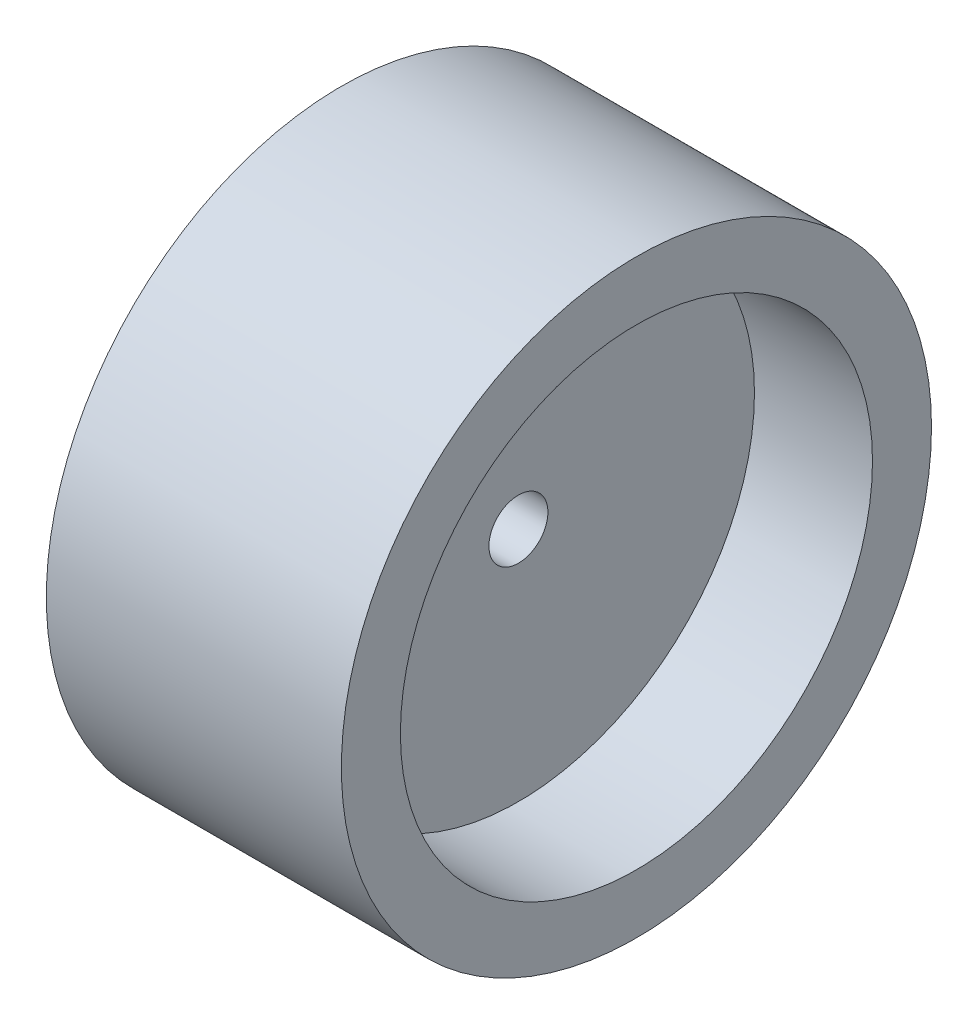
from build123d import *

# Parameters (mm, degrees)
SKETCH1_R           = 50
SKETCH1_R_2         = 5
BOSS_EXTRUDE1_DEPTH = 25
CUT_EXTRUDE1_START  = -5
SKETCH3_R           = 40
CUT_EXTRUDE1_DEPTH  = 20
CUT_EXTRUDE2_START  = 25
SKETCH3_2_R         = 40
CUT_EXTRUDE2_DEPTH  = 20


with BuildPart() as part:
    # Sketch1 → Boss-Extrude1 (new, symmetric)
    with BuildSketch(Plane(origin=(0, 0, 0), x_dir=(0, 0, -1), z_dir=(1, 0, 0))):
        Circle(SKETCH1_R)
        Circle(SKETCH1_R_2, mode=Mode.SUBTRACT)
    extrude(amount=BOSS_EXTRUDE1_DEPTH, both=True)

    # Sketch3 → Cut-Extrude1 (cut)
    with BuildSketch(Plane(origin=(0, 0, 0), x_dir=(0, 0, -1), z_dir=(1, 0, 0)).offset(CUT_EXTRUDE1_START)):
        Circle(SKETCH3_R)
    extrude(amount=-CUT_EXTRUDE1_DEPTH, mode=Mode.SUBTRACT)

    # Sketch3_2 → Cut-Extrude2 (cut)
    with BuildSketch(Plane(origin=(0, 0, 0), x_dir=(0, 0, -1), z_dir=(1, 0, 0)).offset(CUT_EXTRUDE2_START)):
        Circle(SKETCH3_2_R)
    extrude(amount=-CUT_EXTRUDE2_DEPTH, mode=Mode.SUBTRACT)


solid = part.part
